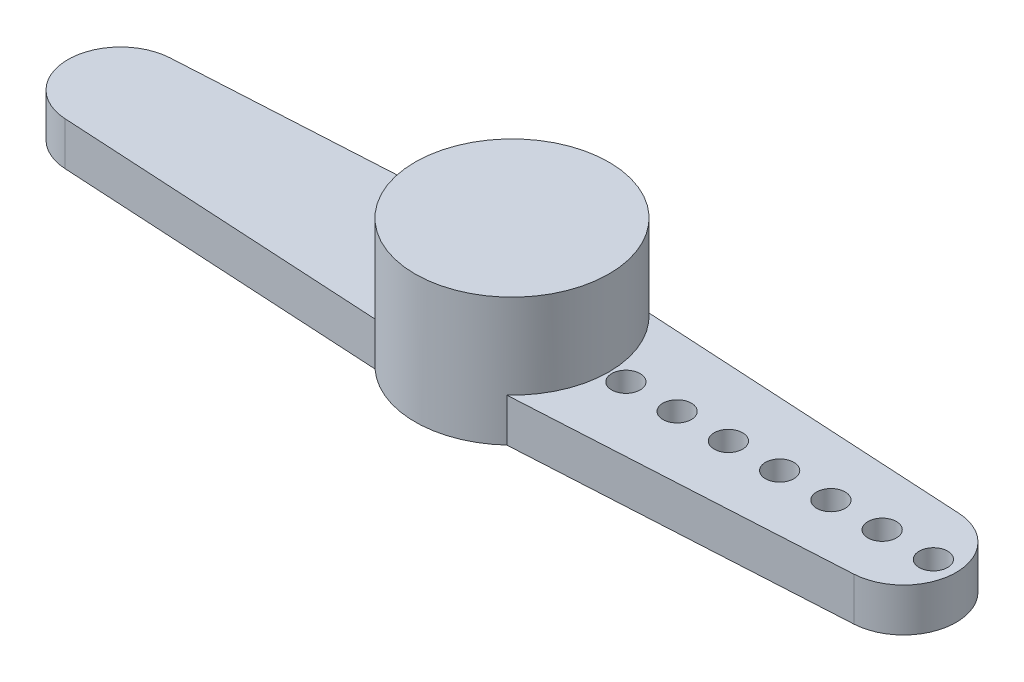
from build123d import *

# Parameters (mm, degrees)
SKETCH_1_R          = 3.405
EXTRUDE_1_DEPTH     = 4.5
EXTRUDE_2_DEPTH     = 1.52
SKETCH_3_R          = 0.5
CUT_EXTRUDE_1_DEPTH = 1.52


with BuildPart() as part:
    # 草图1 → 凸台-拉伸1 (new body)
    with BuildSketch(Plane(origin=(0, 0, 0), x_dir=(1, 0, 0), z_dir=(0, 1, 0))):
        Circle(SKETCH_1_R)
    extrude(amount=EXTRUDE_1_DEPTH)

    # 草图2 → 凸台-拉伸2 (add)
    with BuildSketch(Plane.XZ):
        with BuildLine():
            Line((2.314339904, 2.497569981), (13.854119989, 1.847067684))
            ThreePointArc((13.854119989, 1.847067684), (15.6, 0), (13.854119989, -1.847067684))
            Line((13.854119989, -1.847067684), (2.314339904, -2.497569981))
            ThreePointArc((2.314339904, -2.497569981), (0, -3.405), (-2.314339904, -2.497569981))
            Line((-2.314339904, -2.497569981), (-13.854119989, -1.847067684))
            ThreePointArc((-13.854119989, -1.847067684), (-15.6, 0), (-13.854119989, 1.847067684))
            Line((-13.854119989, 1.847067684), (-2.314339904, 2.497569981))
            ThreePointArc((-2.314339904, 2.497569981), (0, 3.405), (2.314339904, 2.497569981))
        make_face()
    extrude(amount=-EXTRUDE_2_DEPTH)

    # 草图3 → 切除-拉伸1 (cut)
    with BuildSketch(Plane.XZ):
        with Locations((4, 0)):
            Circle(SKETCH_3_R)
        with Locations((5.8, 0)):
            Circle(SKETCH_3_R)
        with Locations((7.6, 0)):
            Circle(SKETCH_3_R)
        with Locations((9.4, 0)):
            Circle(SKETCH_3_R)
        with Locations((11.2, 0)):
            Circle(SKETCH_3_R)
        with Locations((13, 0)):
            Circle(SKETCH_3_R)
        with Locations((14.8, 0)):
            Circle(SKETCH_3_R)
    extrude(amount=-CUT_EXTRUDE_1_DEPTH, mode=Mode.SUBTRACT)


solid = part.part
